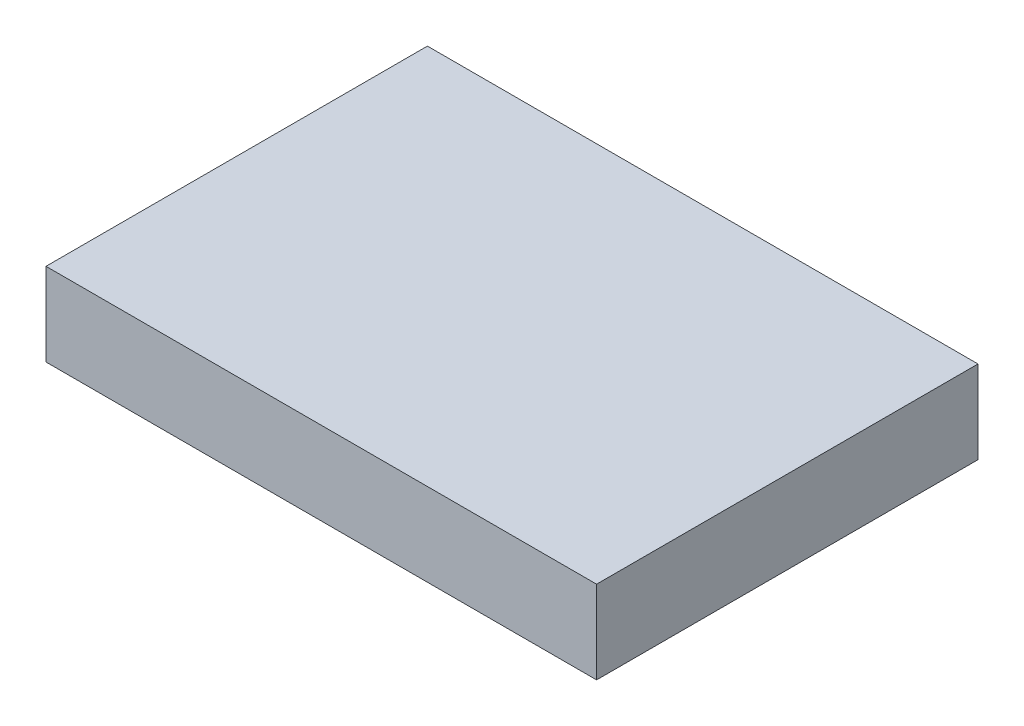
from build123d import *

# Parameters (mm, degrees)
SKETCH1_W           = 210.82
SKETCH1_H           = 146.05
BOSS_EXTRUDE1_DEPTH = 31.75
SHELL1_T            = -3.048


with BuildPart() as part:
    # Sketch1 → Boss-Extrude1 (new body)
    with BuildSketch(Plane(origin=(0, 0, 0), x_dir=(1, 0, 0), z_dir=(0, 1, 0))):
        Rectangle(SKETCH1_W, SKETCH1_H)
    extrude(amount=BOSS_EXTRUDE1_DEPTH)

    # Shell1
    shell1_openings = [part.faces().sort_by_distance(p)[0] for p in [
        (0, 0, 0),
    ]]
    offset(amount=SHELL1_T, openings=shell1_openings, kind=Kind.INTERSECTION)


solid = part.part
